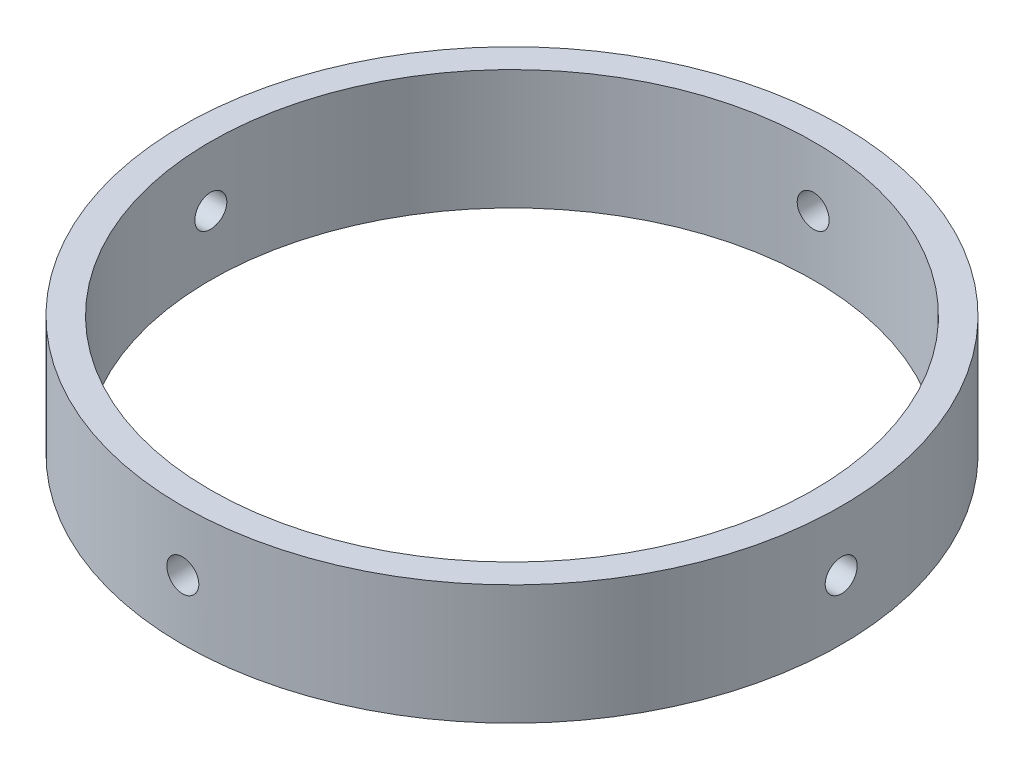
from build123d import *

# Parameters (mm, degrees)
SKETCH1_R               = 41.25
SKETCH1_R_2             = 37.75
BOSS_EXTRUDE1_DEPTH     = 15
CUT_EXTRUDE2_DEPTH      = 50
CUT_EXTRUDE2_DEPTH_BACK = 50
SKETCH2_R               = 2
CUT_EXTRUDE3_DEPTH      = 50
CUT_EXTRUDE3_DEPTH_BACK = 50
SKETCH4_R               = 2


with BuildPart() as part:
    # Sketch1 → Boss-Extrude1 (new body)
    with BuildSketch(Plane(origin=(0, 0, 0), x_dir=(1, 0, 0), z_dir=(0, 1, 0))):
        Circle(SKETCH1_R)
        Circle(SKETCH1_R_2, mode=Mode.SUBTRACT)
    extrude(amount=BOSS_EXTRUDE1_DEPTH)

    # Sketch2 → Cut-Extrude2 (cut, two sides: drawn at the far end of the back side and taken through both)
    with BuildSketch(Plane(origin=(0, 0, 0), x_dir=(0, 0, -1), z_dir=(1, 0, 0)).offset(-CUT_EXTRUDE2_DEPTH_BACK)):
        with Locations((0, 7.5)):
            Circle(SKETCH2_R)
    extrude(amount=CUT_EXTRUDE2_DEPTH + CUT_EXTRUDE2_DEPTH_BACK, mode=Mode.SUBTRACT)

    # Sketch4 → Cut-Extrude3 (cut, two sides: drawn at the far end of the back side and taken through both)
    with BuildSketch(Plane.XY.offset(-CUT_EXTRUDE3_DEPTH_BACK)):
        with Locations((0, 7.5)):
            Circle(SKETCH4_R)
    extrude(amount=CUT_EXTRUDE3_DEPTH + CUT_EXTRUDE3_DEPTH_BACK, mode=Mode.SUBTRACT)


solid = part.part
